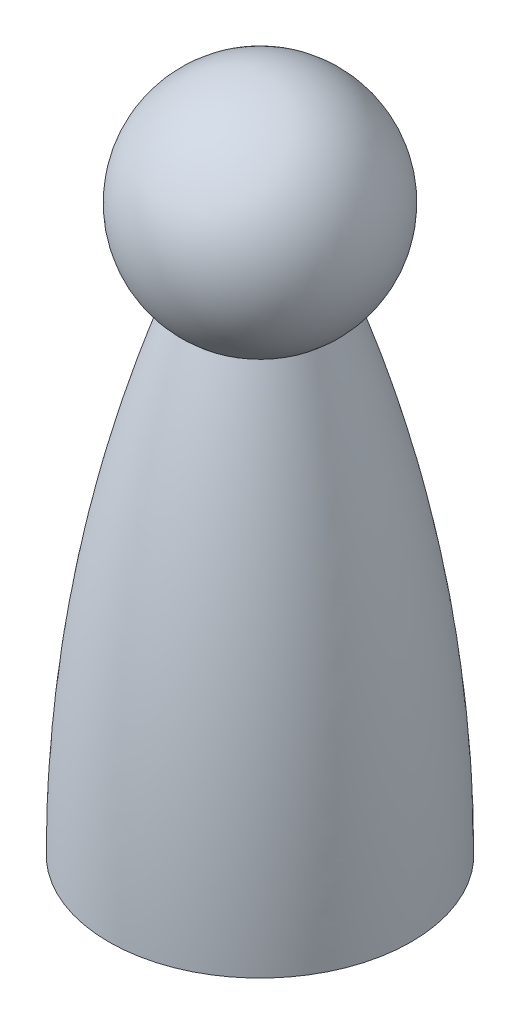
from build123d import *


with BuildPart() as part:
    # Sketch1 → Revolve1 (revolve)
    with BuildSketch(Plane(origin=(0, 0, 0), x_dir=(0, 0, -1), z_dir=(1, 0, 0))):
        with BuildLine():
            Line((0, 88.9), (0, 60.96))
            ThreePointArc((0, 60.96), (4.583469523, 61.733306962), (8.659504703, 63.9676153))
            ThreePointArc((8.659504703, 63.9676153), (13.196693038, 79.513469523), (0, 88.9))
        make_face()
        with BuildLine():
            Line((0, 60.96), (0, 0))
            Line((0, 0), (12.7, 0))
            Line((12.7, 0), (12.7, 3.81))
            Line((12.7, 3.81), (19.05, 3.81))
            add(Edge.make_bspline(
                [(19.05, 3.81), (18.960707091, 34.874332984), (8.659504703, 63.9676153)],
                knots=[0, 0, 0, 1, 1, 1], degree=2))
            ThreePointArc((8.659504703, 63.9676153), (4.583469523, 61.733306962), (0, 60.96))
        make_face()
    revolve(axis=Axis((0, 0, 0), (0, 1, 0)))


solid = part.part
